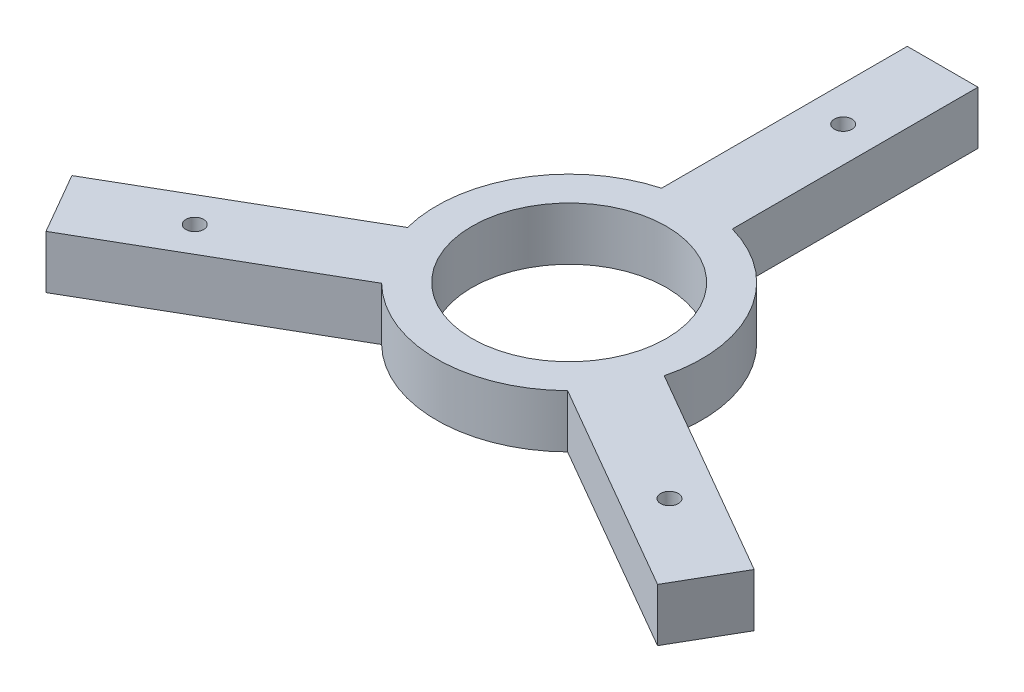
from build123d import *

# Parameters (mm, degrees)
CROQUIS1_R              = 5.5
CROQUIS1_R_2            = 0.5
SALIENTE_EXTRUIR2_DEPTH = 3


with BuildPart() as part:
    # Croquis1 → Saliente-Extruir2 (new body)
    with BuildSketch(Plane(origin=(0, 0, 0), x_dir=(1, 0, 0), z_dir=(0, 1, 0))):
        with BuildLine():
            Line((-19.293466298, -8.829686884), (-17.293466298, -12.293788499))
            Line((-17.293466298, -12.293788499), (-5.259992013, -5.346258881))
            ThreePointArc((-5.259992013, -5.346258881), (0, -7.5), (5.259992013, -5.346258881))
            Line((5.259992013, -5.346258881), (17.293466298, -12.293788499))
            Line((17.293466298, -12.293788499), (19.293466298, -8.829686884))
            Line((19.293466298, -8.829686884), (7.259992013, -1.882157266))
            ThreePointArc((7.259992013, -1.882157266), (6.495190528, 3.75), (2, 7.228416147))
            Line((2, 7.228416147), (2, 21.123475383))
            Line((2, 21.123475383), (-2, 21.123475383))
            Line((-2, 21.123475383), (-2, 7.228416147))
            ThreePointArc((-2, 7.228416147), (-6.495190528, 3.75), (-7.259992013, -1.882157266))
            Line((-7.259992013, -1.882157266), (-19.293466298, -8.829686884))
        make_face()
        Circle(CROQUIS1_R, mode=Mode.SUBTRACT)
        with Locations((-13.423393759, -7.75)):
            Circle(CROQUIS1_R_2, mode=Mode.SUBTRACT)
        with Locations((0, 15.5)):
            Circle(CROQUIS1_R_2, mode=Mode.SUBTRACT)
        with Locations((13.423393759, -7.75)):
            Circle(CROQUIS1_R_2, mode=Mode.SUBTRACT)
    extrude(amount=SALIENTE_EXTRUIR2_DEPTH)


solid = part.part
